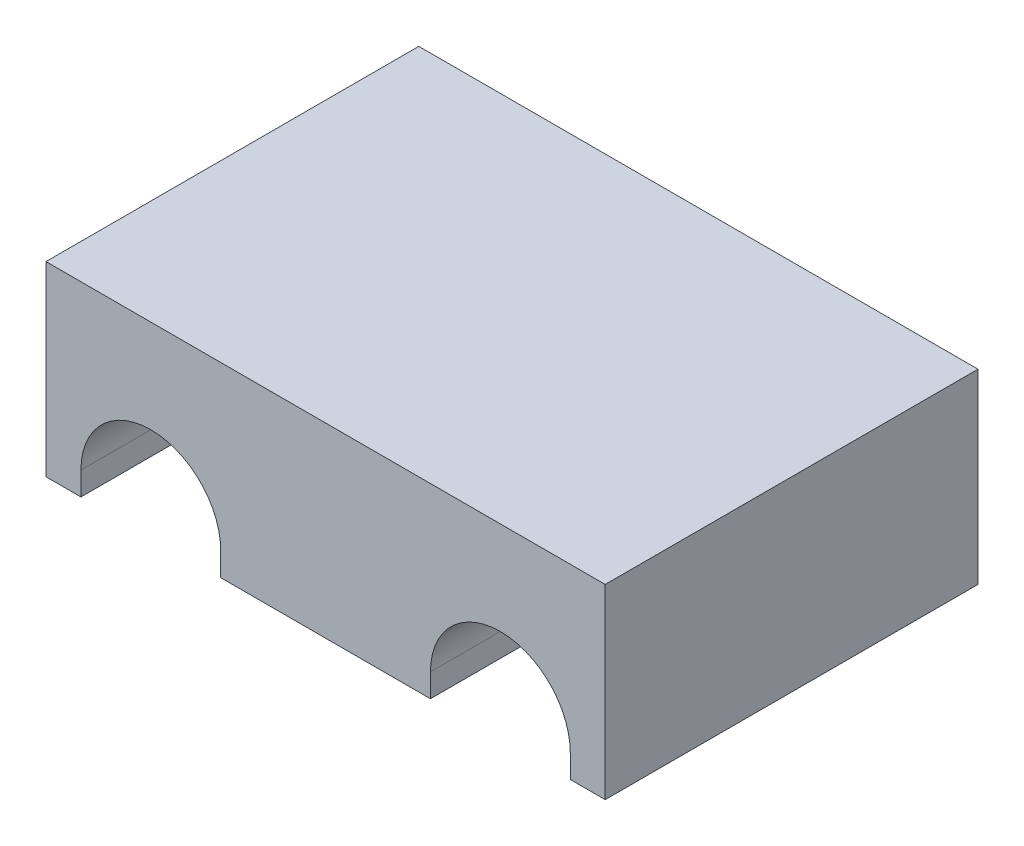
from build123d import *

# Parameters (mm, degrees)
CROQUIS2_W              = 76.2
CROQUIS2_H              = 50.8
CROQUIS2_R              = 9.525
SALIENTE_EXTRUIR1_DEPTH = 50.8
CROQUIS3_W              = 76.2
CROQUIS3_H              = 25.4
CORTAR_EXTRUIR1_DEPTH   = 50.8
CORTAR_EXTRUIR2_DEPTH   = 50.8


with BuildPart() as part:
    # Croquis2 → Saliente-Extruir1 (new body)
    with BuildSketch(Plane.XY):
        with Locations((39.6925, 0)):
            Rectangle(CROQUIS2_W, CROQUIS2_H)
        with Locations((15.88, 0)):
            Circle(CROQUIS2_R, mode=Mode.SUBTRACT)
        with Locations((63.505, 0)):
            Circle(CROQUIS2_R, mode=Mode.SUBTRACT)
    extrude(amount=SALIENTE_EXTRUIR1_DEPTH)

    # Croquis3 → Cortar-Extruir1 (cut)
    with BuildSketch(Plane.XY.offset(50.8)):
        with Locations((39.6925, -12.7)):
            Rectangle(CROQUIS3_W, CROQUIS3_H)
    extrude(amount=-CORTAR_EXTRUIR1_DEPTH, mode=Mode.SUBTRACT)

    # Croquis4 → Cortar-Extruir2 (cut)
    with BuildSketch(Plane.XY.offset(50.8)):
        with BuildLine():
            Line((6.355, 0), (6.355, 3.175))
            ThreePointArc((6.355, 3.175), (15.88, 12.7), (25.405, 3.175))
            Line((25.405, 3.175), (25.405, 0))
            Line((25.405, 0), (6.355, 0))
        make_face()
        with BuildLine():
            Line((73.03, 0), (53.98, 0))
            Line((53.98, 0), (53.98, 3.175))
            ThreePointArc((53.98, 3.175), (63.505, 12.7), (73.03, 3.175))
            Line((73.03, 3.175), (73.03, 0))
        make_face()
    extrude(amount=-CORTAR_EXTRUIR2_DEPTH, mode=Mode.SUBTRACT)


solid = part.part
